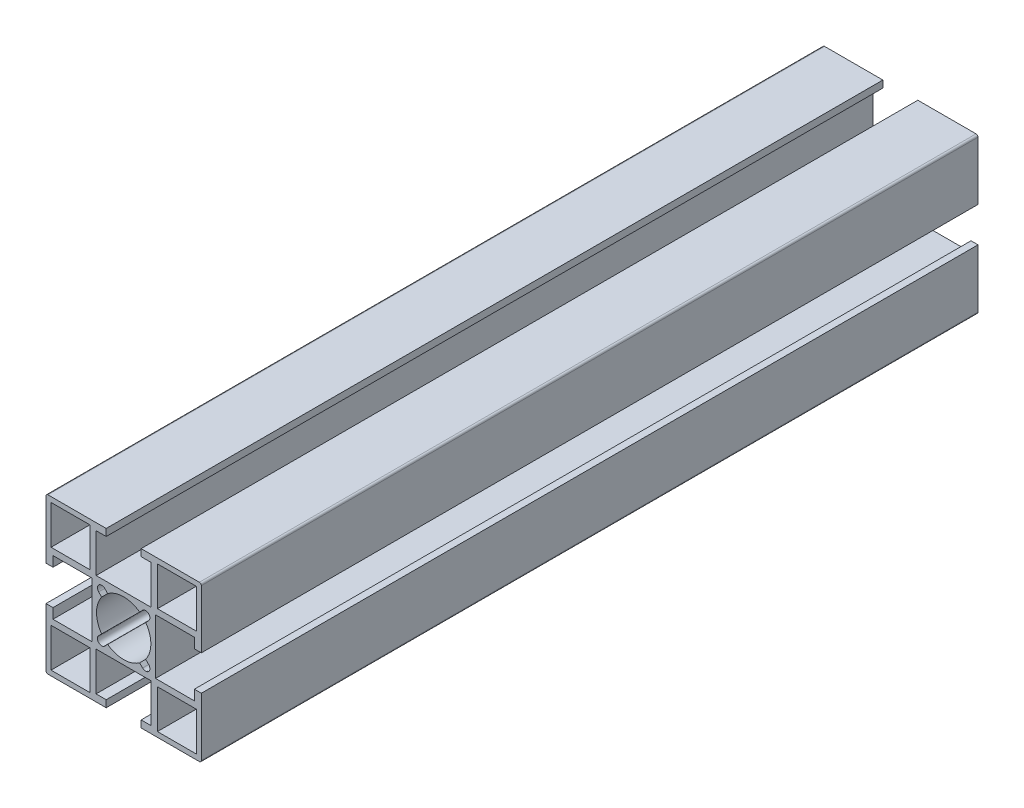
from build123d import *

# Parameters (mm, degrees)
SKETCH1_W                 = 10
SKETCH1_H                 = 10
F_40_X_40A_X_R0_5_1_DEPTH = 200


with BuildPart() as part:
    # Sketch1 → 铝型材 40 X 40A X R0.5(1) (new body)
    with BuildSketch(Plane.YX):
        with BuildLine():
            Line((-19.5, 20), (-4.5, 20))
            Line((-4.5, 20), (-4.5, 18.2))
            Line((-4.5, 18.2), (-7.1, 18.2))
            Line((-7.1, 18.2), (-7.1, 8.2))
            Line((-7.1, 8.2), (7.1, 8.2))
            Line((7.1, 8.2), (7.1, 18.2))
            Line((7.1, 18.2), (4.5, 18.2))
            Line((4.5, 18.2), (4.5, 20))
            Line((4.5, 20), (19.5, 20))
            ThreePointArc((19.5, 20), (19.853553391, 19.853553391), (20, 19.5))
            Line((20, 19.5), (20, 4.5))
            Line((20, 4.5), (18.2, 4.5))
            Line((18.2, 4.5), (18.2, 7.1))
            Line((18.2, 7.1), (8.2, 7.1))
            Line((8.2, 7.1), (8.2, -7.1))
            Line((8.2, -7.1), (18.2, -7.1))
            Line((18.2, -7.1), (18.2, -4.5))
            Line((18.2, -4.5), (20, -4.5))
            Line((20, -4.5), (20, -19.5))
            ThreePointArc((20, -19.5), (19.853553391, -19.853553391), (19.5, -20))
            Line((19.5, -20), (4.5, -20))
            Line((4.5, -20), (4.5, -18.2))
            Line((4.5, -18.2), (7.1, -18.2))
            Line((7.1, -18.2), (7.1, -8.2))
            Line((7.1, -8.2), (-7.1, -8.2))
            Line((-7.1, -8.2), (-7.1, -18.2))
            Line((-7.1, -18.2), (-4.5, -18.2))
            Line((-4.5, -18.2), (-4.5, -20))
            Line((-4.5, -20), (-19.5, -20))
            ThreePointArc((-19.5, -20), (-19.853553391, -19.853553391), (-20, -19.5))
            Line((-20, -19.5), (-20, -4.5))
            Line((-20, -4.5), (-18.2, -4.5))
            Line((-18.2, -4.5), (-18.2, -7.1))
            Line((-18.2, -7.1), (-8.2, -7.1))
            Line((-8.2, -7.1), (-8.2, 7.1))
            Line((-8.2, 7.1), (-18.2, 7.1))
            Line((-18.2, 7.1), (-18.2, 4.5))
            Line((-18.2, 4.5), (-20, 4.5))
            Line((-20, 4.5), (-20, 19.5))
            ThreePointArc((-20, 19.5), (-19.853553391, 19.853553391), (-19.5, 20))
        make_face()
        with BuildLine():
            Line((-4.87903679, 6.434671709), (-4.110433762, 5.66606868))
            ThreePointArc((-4.110433762, 5.66606868), (0, 7), (4.110433762, 5.66606868))
            Line((4.110433762, 5.66606868), (4.87903679, 6.434671709))
            ThreePointArc((4.87903679, 6.434671709), (6.434671709, 6.434671709), (6.434671709, 4.87903679))
            Line((6.434671709, 4.87903679), (5.66606868, 4.110433762))
            ThreePointArc((5.66606868, 4.110433762), (7, 0), (5.66606868, -4.110433762))
            Line((5.66606868, -4.110433762), (6.434671709, -4.87903679))
            ThreePointArc((6.434671709, -4.87903679), (6.434671709, -6.434671709), (4.87903679, -6.434671709))
            Line((4.87903679, -6.434671709), (4.110433762, -5.66606868))
            ThreePointArc((4.110433762, -5.66606868), (0, -7), (-4.110433762, -5.66606868))
            Line((-4.110433762, -5.66606868), (-4.87903679, -6.434671709))
            ThreePointArc((-4.87903679, -6.434671709), (-6.434671709, -6.434671709), (-6.434671709, -4.87903679))
            Line((-6.434671709, -4.87903679), (-5.66606868, -4.110433762))
            ThreePointArc((-5.66606868, -4.110433762), (-7, 0), (-5.66606868, 4.110433762))
            Line((-5.66606868, 4.110433762), (-6.434671709, 4.87903679))
            ThreePointArc((-6.434671709, 4.87903679), (-6.434671709, 6.434671709), (-4.87903679, 6.434671709))
        make_face(mode=Mode.SUBTRACT)
        with Locations((-13.7, 13.7)):
            Rectangle(SKETCH1_W, SKETCH1_H, mode=Mode.SUBTRACT)
        with Locations((13.7, 13.7)):
            Rectangle(SKETCH1_W, SKETCH1_H, mode=Mode.SUBTRACT)
        with Locations((13.7, -13.7)):
            Rectangle(SKETCH1_W, SKETCH1_H, mode=Mode.SUBTRACT)
        with Locations((-13.7, -13.7)):
            Rectangle(SKETCH1_W, SKETCH1_H, mode=Mode.SUBTRACT)
    extrude(amount=F_40_X_40A_X_R0_5_1_DEPTH)


solid = part.part
